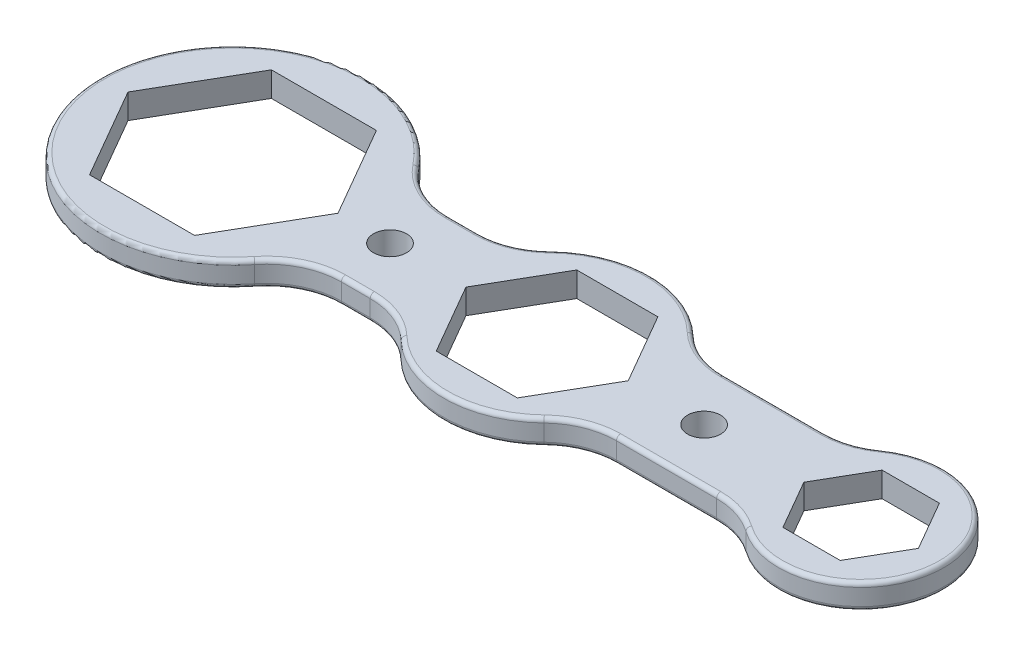
from build123d import *

# Parameters (mm, degrees)
BOSS_EXTRUDE1_DEPTH = 6
CUT_EXTRUDE1_DEPTH  = 7
FILLET1_R           = 18
SKETCH3_R           = 4
CUT_EXTRUDE2_DEPTH  = 7
FILLET3_R           = 1


with BuildPart() as part:
    # Sketch1 → Boss-Extrude1 (new body)
    with BuildSketch(Plane(origin=(0, 0, 0), x_dir=(1, 0, 0), z_dir=(0, 1, 0))):
        with BuildLine():
            Line((-46.759616966, 13), (-21.354156504, 13))
            ThreePointArc((-21.354156504, 13), (0, 25), (21.354156504, 13))
            Line((21.354156504, 13), (60.801315846, 13))
            ThreePointArc((60.801315846, 13), (96, 0), (60.801315846, -13))
            Line((60.801315846, -13), (21.354156504, -13))
            ThreePointArc((21.354156504, -13), (0, -25), (-21.354156504, -13))
            Line((-21.354156504, -13), (-46.759616966, -13))
            ThreePointArc((-46.759616966, -13), (-108, 0), (-46.759616966, 13))
        make_face()
    extrude(amount=BOSS_EXTRUDE1_DEPTH)

    # Sketch2 → Cut-Extrude1 (cut, through all)
    with BuildSketch(Plane(origin=(0, 6, 0), x_dir=(1, 0, 0), z_dir=(0, 1, 0))):
        Polygon((19.629909152, 0), (9.814954576, 17), (-9.814954576, 17), (-19.629909152, 0), (-9.814954576, -17), (9.814954576, -17), align=None)
        Polygon((89.856406461, 0), (82.92820323, 12), (69.07179677, 12), (62.143593539, 0), (69.07179677, -12), (82.92820323, -12), align=None)
        Polygon((-50.596588156, 0), (-63.298294078, 22), (-88.701705922, 22), (-101.403411844, 0), (-88.701705922, -22), (-63.298294078, -22), align=None)
    extrude(amount=-CUT_EXTRUDE1_DEPTH, mode=Mode.SUBTRACT)

    # Fillet1
    fillet1_edges = [part.edges().sort_by_distance(p)[0] for p in [
        (-46.759616966, 3, -13),
        (-21.354156504, 3, -13),
        (21.354156504, 3, -13),
        (60.801315846, 3, -13),
        (60.801315846, 3, 13),
        (21.354156504, 3, 13),
        (-21.354156504, 3, 13),
        (-46.759616966, 3, 13),
    ]]
    fillet(fillet1_edges, radius=FILLET1_R)

    # Sketch3 → Cut-Extrude2 (cut, through all)
    with BuildSketch(Plane(origin=(0, 6, 0), x_dir=(1, 0, 0), z_dir=(0, 1, 0))):
        with Locations(Location((-38, 0, 0), (0, 0, 270))):  # turned: the seam where the file's is
            Circle(SKETCH3_R)
        with Locations(Location((38, 0, 0), (0, 0, 270))):  # turned: the seam where the file's is
            Circle(SKETCH3_R)
    extrude(amount=-CUT_EXTRUDE2_DEPTH, mode=Mode.SUBTRACT)

    # Fillet3
    fillet3_edges = [part.edges().sort_by_distance(p)[0] for p in [
        (-33.28461918, 6, 13),
        (-108, 0, 0),
        (-108, 6, 0),
        (59.485531832, 0, 13.848968115),
        (59.485531832, 6, 13.848968115),
        (59.485531832, 0, -13.848968115),
        (59.485531832, 6, -13.848968115),
        (23.075542543, 0, 14.302973388),
        (23.075542543, 6, 14.302973388),
        (23.075542543, 0, -14.302973388),
        (23.075542543, 6, -14.302973388),
        (-23.075542543, 0, -14.302973388),
        (-23.075542543, 6, -14.302973388),
        (-23.075542543, 0, 14.302973388),
        (-23.075542543, 6, 14.302973388),
        (-44.615927607, 0, 14.8),
        (-44.615927607, 6, 14.8),
        (-44.615927607, 0, -14.8),
        (-44.615927607, 6, -14.8),
        (96, 0, 0),
        (96, 6, 0),
        (41.911033938, 0, 13),
        (41.911033938, 6, 13),
        (41.911033938, 0, -13),
        (41.911033938, 6, -13),
        (0, 0, 25),
        (0, 6, 25),
        (0, 0, -25),
        (0, 6, -25),
        (-33.28461918, 0, -13),
        (-33.28461918, 6, -13),
        (-33.28461918, 0, 13),
    ]]
    fillet(fillet3_edges, radius=FILLET3_R)


solid = part.part
